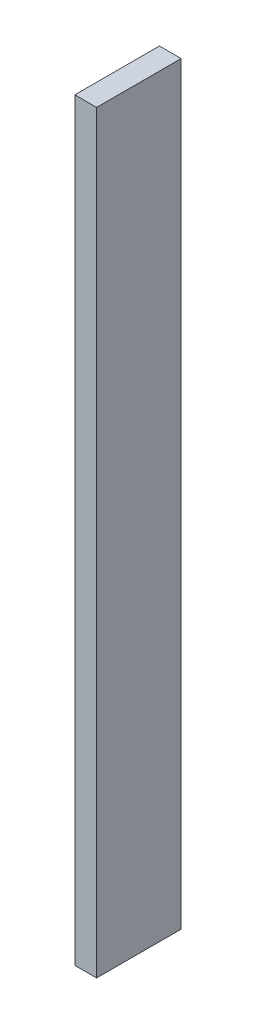
from build123d import *

# Parameters (mm, degrees)
ESQUISSE1_W        = 9
ESQUISSE1_H        = 312
BOSS_EXTRU_1_DEPTH = 35


with BuildPart() as part:
    # Esquisse1 → Boss.-Extru.1 (new body)
    with BuildSketch(Plane.XY):
        with Locations((-62.35, 0)):
            Rectangle(ESQUISSE1_W, ESQUISSE1_H)
    extrude(amount=BOSS_EXTRU_1_DEPTH)


solid = part.part
